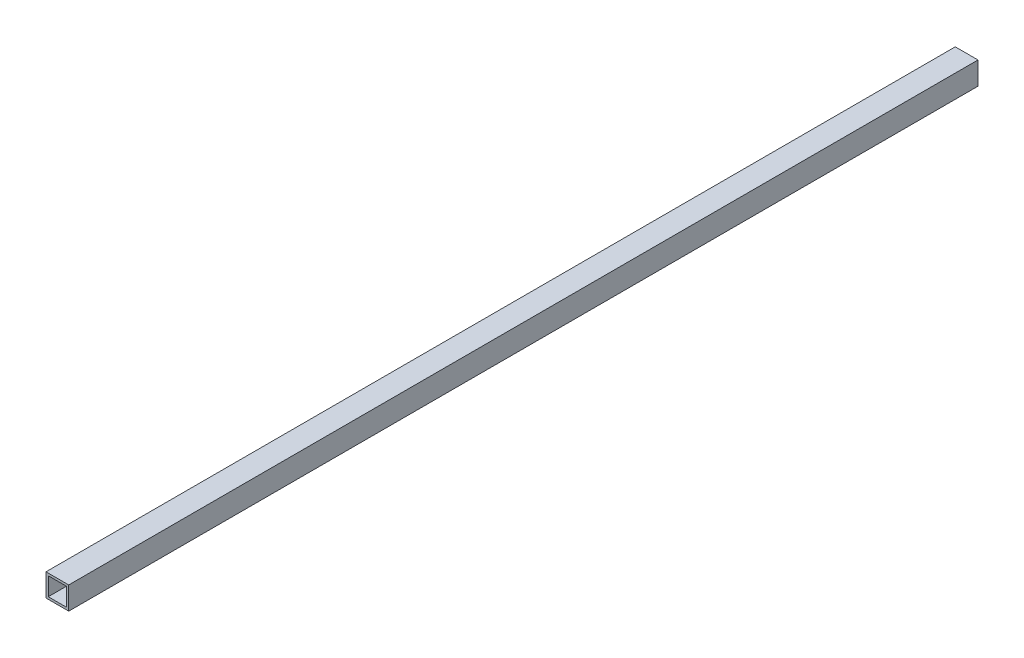
from build123d import *

# Parameters (mm, degrees)
SKETCH2_W           = 10
SKETCH2_H           = 10
BOSS_EXTRUDE1_DEPTH = 400
SKETCH3_W           = 8
SKETCH3_H           = 8
CUT_EXTRUDE1_DEPTH  = 400


with BuildPart() as part:
    # Sketch2 → Boss-Extrude1 (new body)
    with BuildSketch(Plane.XY):
        Rectangle(SKETCH2_W, SKETCH2_H)
    extrude(amount=BOSS_EXTRUDE1_DEPTH)

    # Sketch3 → Cut-Extrude1 (cut)
    with BuildSketch(Plane.XY.offset(400)):
        Rectangle(SKETCH3_W, SKETCH3_H)
    extrude(amount=-CUT_EXTRUDE1_DEPTH, mode=Mode.SUBTRACT)


solid = part.part
